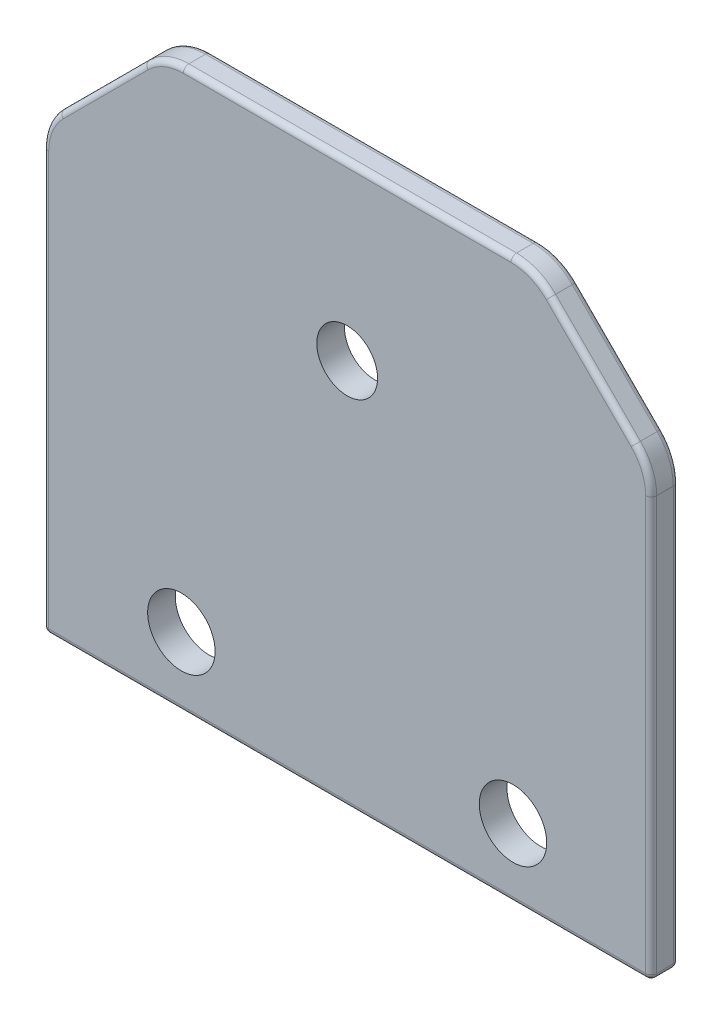
from build123d import *

# Parameters (mm, degrees)
SKETCH1_R           = 6.1
SKETCH1_R_2         = 5.5
BOSS_EXTRUDE1_DEPTH = 5
FILLET1_R           = 10
FILLET2_R           = 1


with BuildPart() as part:
    # Sketch1 → Boss-Extrude1 (new body)
    with BuildSketch(Plane.XY):
        Polygon((0, 0), (110, 0), (110, 80), (88.786796564, 101.213203436), (21.213203436, 101.213203436), (0, 80), align=None)
        with Locations((25, 12.5)):
            Circle(SKETCH1_R, mode=Mode.SUBTRACT)
        with Locations((85, 12.5)):
            Circle(SKETCH1_R, mode=Mode.SUBTRACT)
        with Locations((55, 70)):
            Circle(SKETCH1_R_2, mode=Mode.SUBTRACT)
    extrude(amount=BOSS_EXTRUDE1_DEPTH)

    # Fillet1
    fillet1_edges = [part.edges().sort_by_distance(p)[0] for p in [
        (110, 80, 2.5),
        (0, 80, 2.5),
        (21.213203436, 101.213203436, 2.5),
        (88.786796564, 101.213203436, 2.5),
    ]]
    fillet(fillet1_edges, radius=FILLET1_R)

    # Fillet2
    fillet2_edges = [part.edges().sort_by_distance(p)[0] for p in [
        (110, 37.928932188, 0),
        (55, 0, 0),
        (0, 37.928932188, 0),
        (110, 0, 2.5),
        (0, 0, 2.5),
        (0, 37.928932188, 5),
        (55, 0, 5),
        (99.393398282, 90.606601718, 0),
        (99.393398282, 90.606601718, 5),
        (10.606601718, 90.606601718, 0),
        (55, 101.213203436, 0),
        (21.528504736, 100.451998761, 0),
        (110, 37.928932188, 5),
        (0.761204675, 79.6846987, 0),
        (88.471495264, 100.451998761, 0),
        (109.238795325, 79.6846987, 0),
        (55, 101.213203436, 5),
        (10.606601718, 90.606601718, 5),
        (21.528504736, 100.451998761, 5),
        (0.761204675, 79.6846987, 5),
        (88.471495264, 100.451998761, 5),
        (109.238795325, 79.6846987, 5),
    ]]
    fillet(fillet2_edges, radius=FILLET2_R)


solid = part.part
